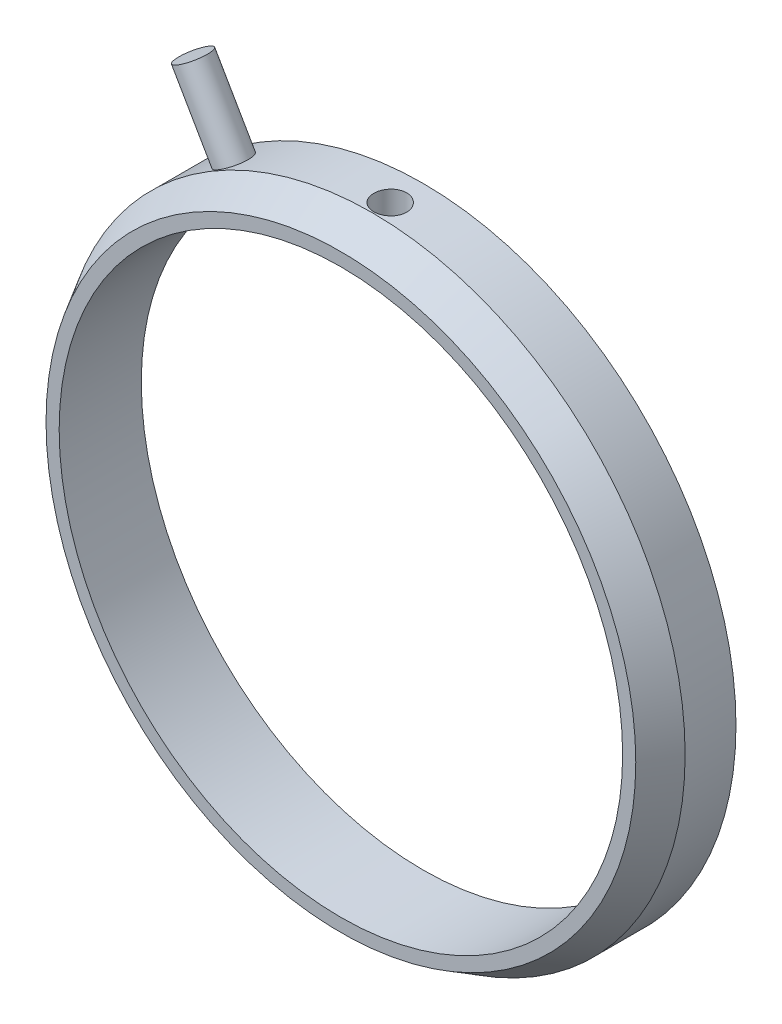
from build123d import *

# Parameters (mm, degrees)
SKETCH1_R           = 19.05
BOSS_EXTRUDE1_DEPTH = 5
CHAMFER1_SIZE       = 1.905
CHAMFER1_SIZE2      = 1.099852263
SKETCH2_R           = 1
CUT_EXTRUDE1_DEPTH  = 30
SKETCH5_R           = 17.15
CUT_EXTRUDE2_DEPTH  = 15


with BuildPart() as part:
    # Sketch1 → Boss-Extrude1 (new body)
    with BuildSketch(Plane.XY):
        Circle(SKETCH1_R)
    extrude(amount=BOSS_EXTRUDE1_DEPTH)

    # Chamfer1
    chamfer1_edges = [part.edges().sort_by_distance(p)[0] for p in [
        (-19.05, 0, 5),
    ]]
    chamfer1_side = [part.faces().sort_by_distance(p)[0] for p in [
        (-19.05, 0, 2.5),
    ]]
    chamfer(chamfer1_edges, length=CHAMFER1_SIZE, length2=CHAMFER1_SIZE2, reference=chamfer1_side[0])

    # Sketch4 → Revolve-Thin1 (revolve)
    with BuildSketch(Plane.XY.offset(2)):
        Polygon((0, 0), (-12, 20.784609691), (-12.866025404, 20.284609691), (-0.866025404, -0.5), align=None)
    revolve(axis=Axis((0, 0, 2), (-0.5, 0.866025404, 0)))

    # Sketch2 → Cut-Extrude1 (cut)
    with BuildSketch(Plane(origin=(0, 0, 0), x_dir=(1, 0, 0), z_dir=(0, 1, 0))):
        with Locations((0, -2)):
            Circle(SKETCH2_R)
    extrude(amount=CUT_EXTRUDE1_DEPTH, mode=Mode.SUBTRACT)

    # Sketch5 → Cut-Extrude2 (cut)
    with BuildSketch(Plane.XY.offset(5)):
        Circle(SKETCH5_R)
    extrude(amount=-CUT_EXTRUDE2_DEPTH, mode=Mode.SUBTRACT)


solid = part.part
